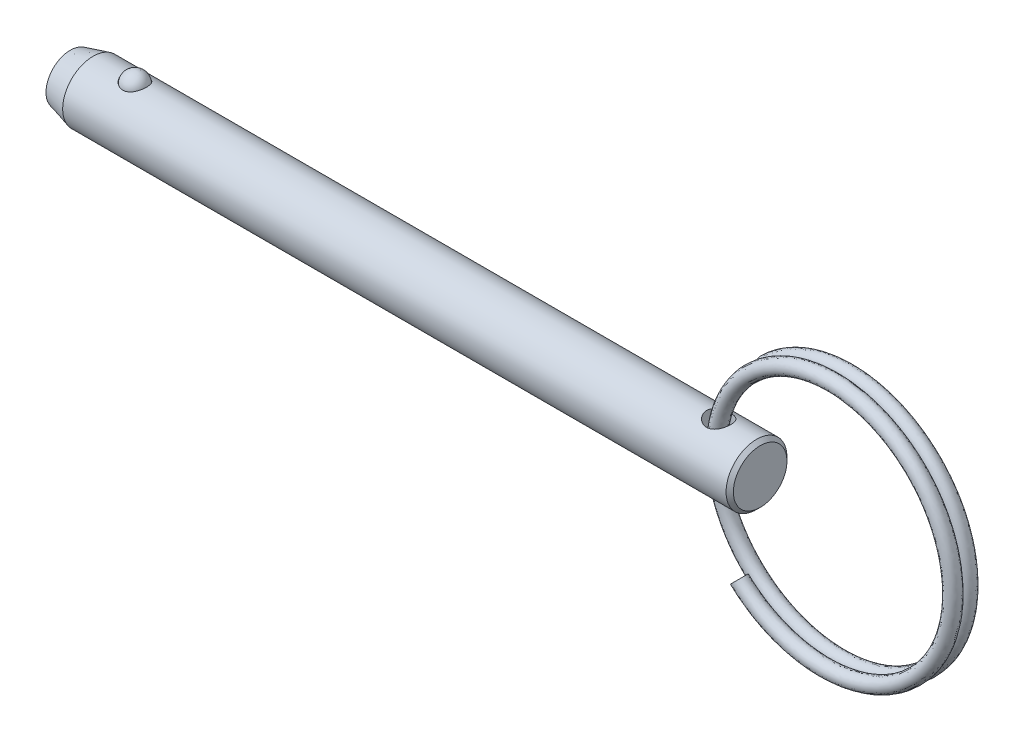
from build123d import *

# Parameters (mm, degrees)
SKETCH4_W          = 1.27
SKETCH4_H          = 6.35
SWEEP1_PITCH       = 1.5494
SWEEP1_HEIGHT      = 1.355725
SWEEP1_RADIUS      = 13.462
SKETCH6_R          = 0.762
SWEEP2_PITCH       = 1.5494
SWEEP2_HEIGHT      = 1.355725
SWEEP2_RADIUS      = 13.462
SWEEP2_START_ANGLE = -180
SKETCH6_2_R        = 0.762


with BuildPart() as part:
    # Sketch1 → Revolve1 (revolve)
    with BuildSketch(Plane.XY):
        Polygon((35.9664, 2.794), (35.5854, 3.175), (-33.596547737, 3.175), (-35.9664, 2.54), (-35.9664, 0), (35.9664, 0), align=None)
    revolve(axis=Axis((35.9664, 0, 0), (1, 0, 0)))

    # Sketch2 → Cut-Revolve1 (revolve, cut)
    with BuildSketch(Plane.XY):
        with BuildLine():
            Line((-27.974582051, 2.8575), (-30.489182051, 2.8575))
            ThreePointArc((-30.489182051, 2.8575), (-29.231882051, 4.1148), (-27.974582051, 2.8575))
        make_face()
    revolve(axis=Axis((-27.974582051, 2.8575, 0), (1, 0, 0)), mode=Mode.SUBTRACT)

    # Sketch4 → Cut-Revolve2 (revolve, cut)
    with BuildSketch(Plane.XY):
        with Locations((32.2834, 0)):
            Rectangle(SKETCH4_W, SKETCH4_H)
    revolve(axis=Axis((31.6484, -3.175, 0), (0, 1, 0)), mode=Mode.SUBTRACT)


with BuildPart() as body_2:
    # Sketch3 → Revolve2 (revolve)
    with BuildSketch(Plane.XY):
        with BuildLine():
            Line((-27.999982051, 2.8575), (-30.463782051, 2.8575))
            ThreePointArc((-30.463782051, 2.8575), (-29.231882051, 4.0894), (-27.999982051, 2.8575))
        make_face()
    revolve(axis=Axis((-27.999982051, 2.8575, 0), (1, 0, 0)))


with BuildPart() as body_3:
    # Sweep1: sweep along a helix
    with BuildLine() as sweep1_path:
        Helix(SWEEP1_PITCH, SWEEP1_HEIGHT, SWEEP1_RADIUS, center=(44.133425091, 0, 0), direction=(0, 0, -1), lefthand=True)
    # Sketch6 → Sweep1 (sweep)
    with BuildSketch(Plane(origin=(114.003847968, 0, 0), x_dir=(0, 0, -1), z_dir=(0, 1, 0))):
        with Locations((0, 82.570422877)):
            Circle(SKETCH6_R)
    sweep(path=sweep1_path.line, is_frenet=True)

    # Sweep2: sweep along a helix
    with BuildLine() as sweep2_path:
        add(Helix(SWEEP2_PITCH, SWEEP2_HEIGHT, SWEEP2_RADIUS, center=(44.133425091, 0, 0), direction=(0, 0, 1), lefthand=True, mode=Mode.PRIVATE).rotate(Axis((44.133425091, 0, 0), (0, 0, 1)), SWEEP2_START_ANGLE))
    # Sketch6_2 → Sweep2 (sweep)
    with BuildSketch(Plane(origin=(114.003847968, 0, 0), x_dir=(0, 0, -1), z_dir=(0, 1, 0))):
        with Locations((0, 82.570422877)):
            Circle(SKETCH6_2_R)
    sweep(path=sweep2_path.line, is_frenet=True)


solid = Compound([part.part, body_2.part, body_3.part])
